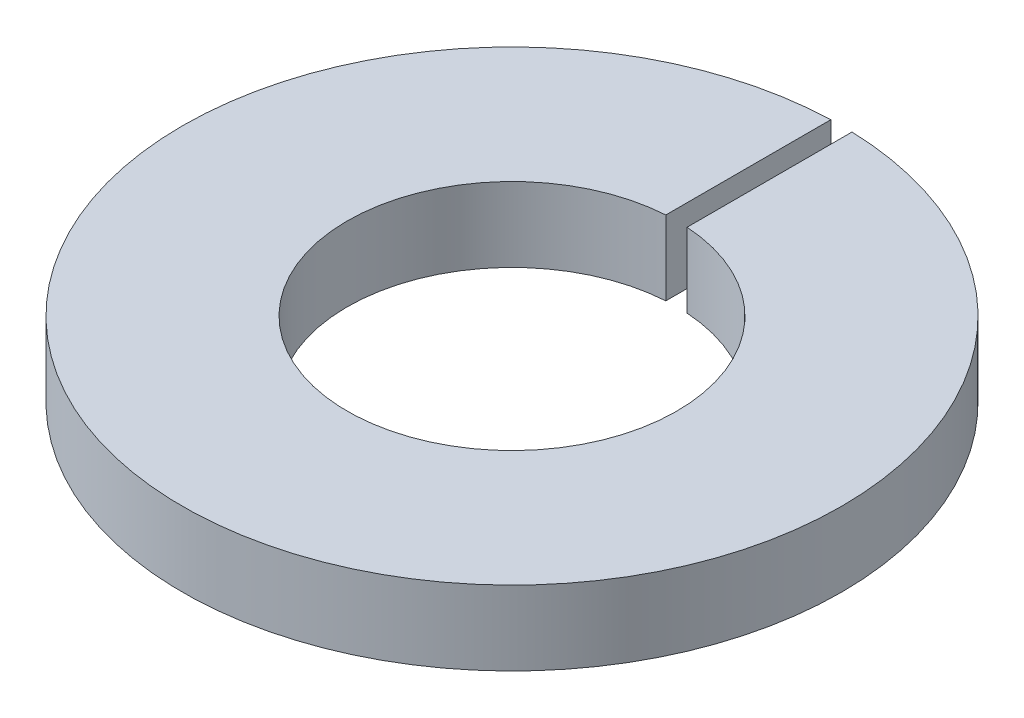
from build123d import *

# Parameters (mm, degrees)
RESSALTO_EXTRUS_O1_DEPTH = 0.7


with BuildPart() as part:
    # Esboço1 → Ressalto-extrusão1 (new body)
    with BuildSketch(Plane(origin=(0, 0, 0), x_dir=(1, 0, 0), z_dir=(0, 1, 0))):
        with BuildLine():
            Line((-0.1, 3.098386677), (-0.1, 1.54677083))
            ThreePointArc((-0.1, 1.54677083), (0, -1.55), (0.1, 1.54677083))
            Line((0.1, 1.54677083), (0.1, 3.098386677))
            ThreePointArc((0.1, 3.098386677), (0, -3.1), (-0.1, 3.098386677))
        make_face()
    extrude(amount=RESSALTO_EXTRUS_O1_DEPTH)


solid = part.part
